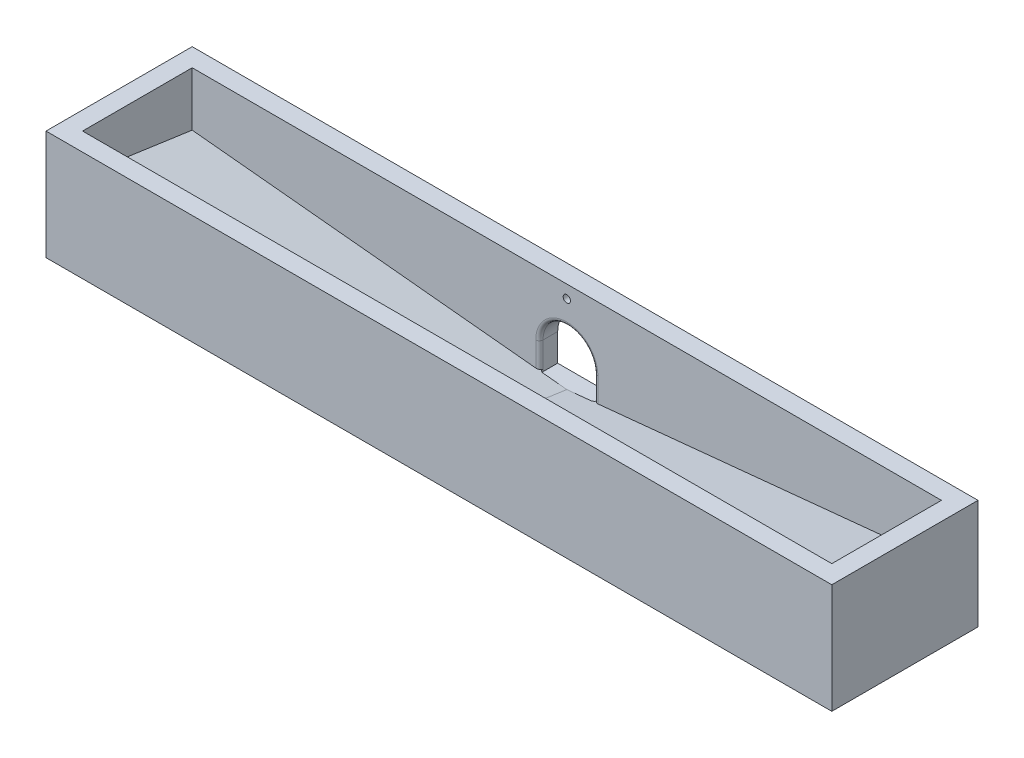
from build123d import *

# Parameters (mm, degrees)
ESQUISSE2_W              = 430
ESQUISSE2_H              = 60
BOSS_EXTRU_1_DEPTH       = 80
ESQUISSE3_W              = 410
ESQUISSE3_H              = 60
ENL_V_MAT_EXTRU_2_DEPTH  = 50
BOSS_EXTRU_3_DEPTH       = 60
BOSS_EXTRU_4_DEPTH       = 20
ESQUISSE12_W             = 37.299463168
ESQUISSE12_H             = 2.901511437
ENL_V_MAT_EXTRU_3_DEPTH  = 80
ESQUISSE14_W             = 217.702790891
ESQUISSE14_H             = 66.731599488
ENL_V_MAT_EXTRU_4_DEPTH  = 80
ESQUISSE16_W             = 132.026208669
ESQUISSE16_H             = 23.789258621
ENL_V_MAT_EXTRU_5_DEPTH  = 80
ESQUISSE17_W             = 231.982221262
ESQUISSE17_H             = 63.124798286
ENL_V_MAT_EXTRU_6_DEPTH  = 80
ESQUISSE18_R             = 15
ENL_V_MAT_EXTRU_7_DEPTH  = 80
ENL_V_MAT_EXTRU_8_DEPTH  = 10
CONG_3_R                 = 2
CONG_4_R                 = 2
ESQUISSE26_W             = 44.72135955
ESQUISSE26_H             = 10
BOSS_EXTRU_5_DEPTH       = 10
ENL_V_MAT_EXTRU_9_DEPTH  = 10
ESQUISSE27_R             = 2
ENL_V_MAT_EXTRU_11_DEPTH = 10


with BuildPart() as part:
    # Esquisse2 → Boss.-Extru.1 (new body)
    with BuildSketch(Plane.XY):
        with Locations((4.509056244, 59.566253575)):
            Rectangle(ESQUISSE2_W, ESQUISSE2_H)
    extrude(amount=BOSS_EXTRU_1_DEPTH)

    # Esquisse3 → Enlèv. mat.-Extru.2 (cut)
    with BuildSketch(Plane(origin=(0, 89.566253575, 0), x_dir=(1, 0, 0), z_dir=(0, 1, 0))):
        with Locations((4.509056244, -40)):
            Rectangle(ESQUISSE3_W, ESQUISSE3_H)
    extrude(amount=-ENL_V_MAT_EXTRU_2_DEPTH, mode=Mode.SUBTRACT)

    # Esquisse5 → Boss.-Extru.3 (add)
    with BuildSketch(Plane.XY.offset(10)):
        Polygon((-200.490943756, 59.566253575), (-200.490943756, 39.566253575), (4.509056244, 39.566253575), align=None)
        Polygon((209.509056244, 59.566253575), (4.509056244, 39.566253575), (209.509056244, 39.566253575), align=None)
    extrude(amount=BOSS_EXTRU_3_DEPTH)

    # Esquisse11 → Boss.-Extru.4 (add)
    with BuildSketch(Plane(origin=(3.732634391, 37.450765056, -5.350109294), x_dir=(0.995167757, -0.097202432, 0.013886062), z_dir=(0.098189284, 0.985165817, -0.140737974))):
        Polygon((0.78019193, -15.495008178), (-209.853755734, -12.986939636), (-207.594167279, -81.787183383), (2.874639564, -83.936671883), align=None)
    boss_extru_4 = extrude(amount=-BOSS_EXTRU_4_DEPTH)

    # Esquisse12 → Enlèv. mat.-Extru.3 (cut)
    with BuildSketch(Plane(origin=(0, 89.566253575, 0), x_dir=(1, 0, 0), z_dir=(0, 1, 0))):
        with Locations((-6.67152918, -81.450755719)):
            Rectangle(ESQUISSE12_W, ESQUISSE12_H)
    extrude(amount=-ENL_V_MAT_EXTRU_3_DEPTH, mode=Mode.SUBTRACT)

    # Esquisse14 → Enlèv. mat.-Extru.4 (cut)
    with BuildSketch(Plane.XY.offset(80)):
        with Locations((-32.350917278, -3.799546169)):
            Rectangle(ESQUISSE14_W, ESQUISSE14_H)
    extrude(amount=-ENL_V_MAT_EXTRU_4_DEPTH, mode=Mode.SUBTRACT)

    # Symétrie3: Boss.-Extru.4 across plane
    add(boss_extru_4.mirror(Plane(origin=(4.509056244, 0, 0), x_dir=(0, 0, 1), z_dir=(1, 0, 0))))

    # Esquisse16 → Enlèv. mat.-Extru.5 (cut)
    with BuildSketch(Plane(origin=(0, 89.566253575, 0), x_dir=(1, 0, 0), z_dir=(0, 1, 0))):
        with Locations((17.978222552, -91.89462931)):
            Rectangle(ESQUISSE16_W, ESQUISSE16_H)
    extrude(amount=-ENL_V_MAT_EXTRU_5_DEPTH, mode=Mode.SUBTRACT)

    # Esquisse17 → Enlèv. mat.-Extru.6 (cut)
    with BuildSketch(Plane.XY.offset(80)):
        with Locations((69.126673961, -1.996145568)):
            Rectangle(ESQUISSE17_W, ESQUISSE17_H)
    extrude(amount=-ENL_V_MAT_EXTRU_6_DEPTH, mode=Mode.SUBTRACT)

    # Esquisse18 → Enlèv. mat.-Extru.7 (cut)
    with BuildSketch(Plane.XY.offset(10)):
        with Locations((4.509056244, 54.566253575)):
            Circle(ESQUISSE18_R)
    extrude(amount=-ENL_V_MAT_EXTRU_7_DEPTH, mode=Mode.SUBTRACT)

    # Esquisse20 → Enlèv. mat.-Extru.8 (cut)
    with BuildSketch(Plane(origin=(0, 0, 0), x_dir=(-1, 0, 0), z_dir=(0, 0, -1))):
        Polygon((-19.509056244, 54.566253575), (-19.509056244, 39.566253575), (-4.509056244, 39.566253575), (10.490943756, 39.566253575), (10.490943756, 54.566253575), align=None)
    extrude(amount=-ENL_V_MAT_EXTRU_8_DEPTH, mode=Mode.SUBTRACT)

    # Congé3
    cong_3_edges = [part.edges().sort_by_distance(p)[0] for p in [
        (4.509056244, 69.566253575, 10),
        (-10.490943756, 47.81376188, 10),
        (19.509056244, 47.81376188, 10),
    ]]
    fillet(cong_3_edges, radius=CONG_3_R)

    # Congé4
    cong_4_edges = [part.edges().sort_by_distance(p)[0] for p in [
        (19.509056244, 40.31376188, 10),
        (-10.490943756, 40.31376188, 10),
    ]]
    fillet(cong_4_edges, radius=CONG_4_R)

    # Esquisse26 → Boss.-Extru.5 (add)
    with BuildSketch(Plane.XZ.offset(-29.566253575)):
        with Locations((4.509056244, 5)):
            Rectangle(ESQUISSE26_W, ESQUISSE26_H)
    extrude(amount=BOSS_EXTRU_5_DEPTH)

    # Esquisse24 → Enlèv. mat.-Extru.9 (cut)
    with BuildSketch(Plane(origin=(0, 0, 0), x_dir=(-1, 0, 0), z_dir=(0, 0, -1))):
        with BuildLine():
            ThreePointArc((-2.510656885, 24.646253575), (-4.509056244, 26.566253575), (-6.507455604, 24.646253575))
            ThreePointArc((-6.507455604, 24.646253575), (-4.509056244, 24.566253575), (-2.510656885, 24.646253575))
        make_face()
        with BuildLine():
            ThreePointArc((-2.510656885, 24.646253575), (-4.509056244, 24.566253575), (-6.507455604, 24.646253575))
            ThreePointArc((-6.507455604, 24.646253575), (-4.54906425, 22.566653775), (-2.509056244, 24.566253575))
            ThreePointArc((-2.509056244, 24.566253575), (-2.509456444, 24.60626158), (-2.510656885, 24.646253575))
        make_face()
    extrude(amount=-ENL_V_MAT_EXTRU_9_DEPTH, mode=Mode.SUBTRACT)

    # Esquisse27 → Enlèv. mat.-Extru.11 (cut)
    with BuildSketch(Plane(origin=(0, 0, 0), x_dir=(-1, 0, 0), z_dir=(0, 0, -1))):
        with Locations((-4.509056244, 82.566253575)):
            Circle(ESQUISSE27_R)
    extrude(amount=-ENL_V_MAT_EXTRU_11_DEPTH, mode=Mode.SUBTRACT)


solid = part.part
